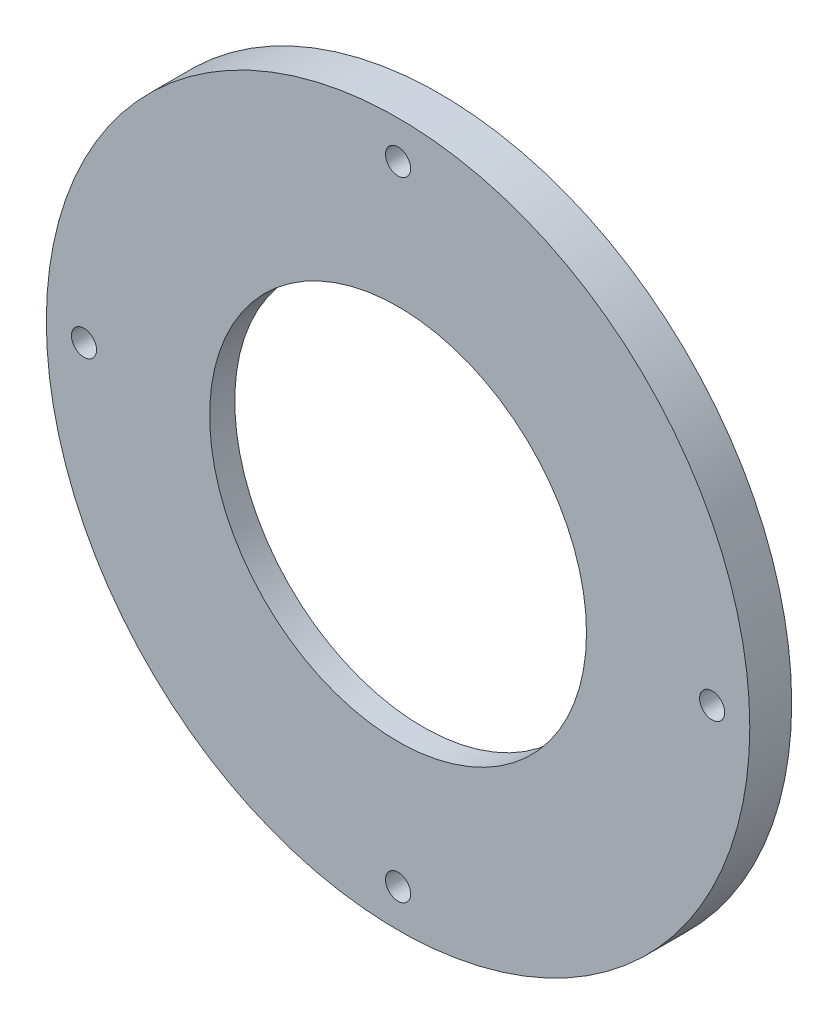
from build123d import *

# Parameters (mm, degrees)
SKETCH_1_R          = 42
SKETCH_1_R_2        = 1.5
SKETCH_1_R_3        = 32.6
SKETCH_1_R_4        = 22.5
EXTRUDE_1_DEPTH     = 5
SKETCH_1_4_R        = 32.6
CUT_EXTRUDE_1_DEPTH = 2


with BuildPart() as part:
    # 草图1 → 凸台-拉伸1 (new body)
    # profile 1 of 2: a face of its own
    with BuildSketch(Plane.XY):
        Circle(SKETCH_1_R)
        with Locations((0, -37.5)):
            Circle(SKETCH_1_R_2, mode=Mode.SUBTRACT)
        Circle(SKETCH_1_R_3, mode=Mode.SUBTRACT)
        with Locations((37.5, 0)):
            Circle(SKETCH_1_R_2, mode=Mode.SUBTRACT)
        with Locations((-37.5, 0)):
            Circle(SKETCH_1_R_2, mode=Mode.SUBTRACT)
        with Locations((0, 37.5)):
            Circle(SKETCH_1_R_2, mode=Mode.SUBTRACT)
    # profile 2 of 2: a face of its own
    with BuildSketch(Plane.XY):
        Circle(SKETCH_1_R_3)
        Circle(SKETCH_1_R_4, mode=Mode.SUBTRACT)
    extrude(amount=EXTRUDE_1_DEPTH)

    # 草图1<4> → 切除-拉伸1 (cut)
    with BuildSketch(Plane.XY):
        Circle(SKETCH_1_4_R)
    extrude(amount=CUT_EXTRUDE_1_DEPTH, mode=Mode.SUBTRACT)


solid = part.part
